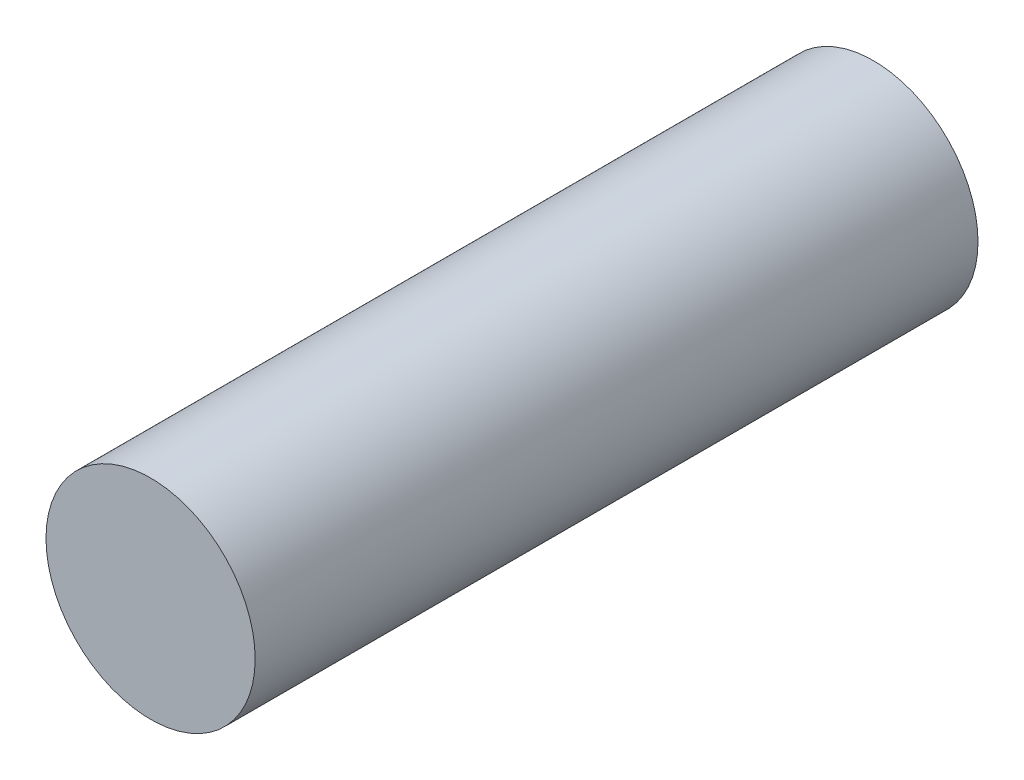
from build123d import *

# Parameters (mm, degrees)
SKETCH1_R           = 7.35
BOSS_EXTRUDE1_DEPTH = 50.8
SKETCH2_R           = 1.985
CUT_EXTRUDE1_DEPTH  = 6.35


with BuildPart() as part:
    # Sketch1 → Boss-Extrude1 (new body)
    with BuildSketch(Plane.XY):
        Circle(SKETCH1_R)
    extrude(amount=BOSS_EXTRUDE1_DEPTH)

    # Sketch2 → Cut-Extrude1 (cut)
    with BuildSketch(Plane(origin=(0, 0, 0), x_dir=(-1, 0, 0), z_dir=(0, 0, -1))):
        Circle(SKETCH2_R)
    extrude(amount=-CUT_EXTRUDE1_DEPTH, mode=Mode.SUBTRACT)


solid = part.part
